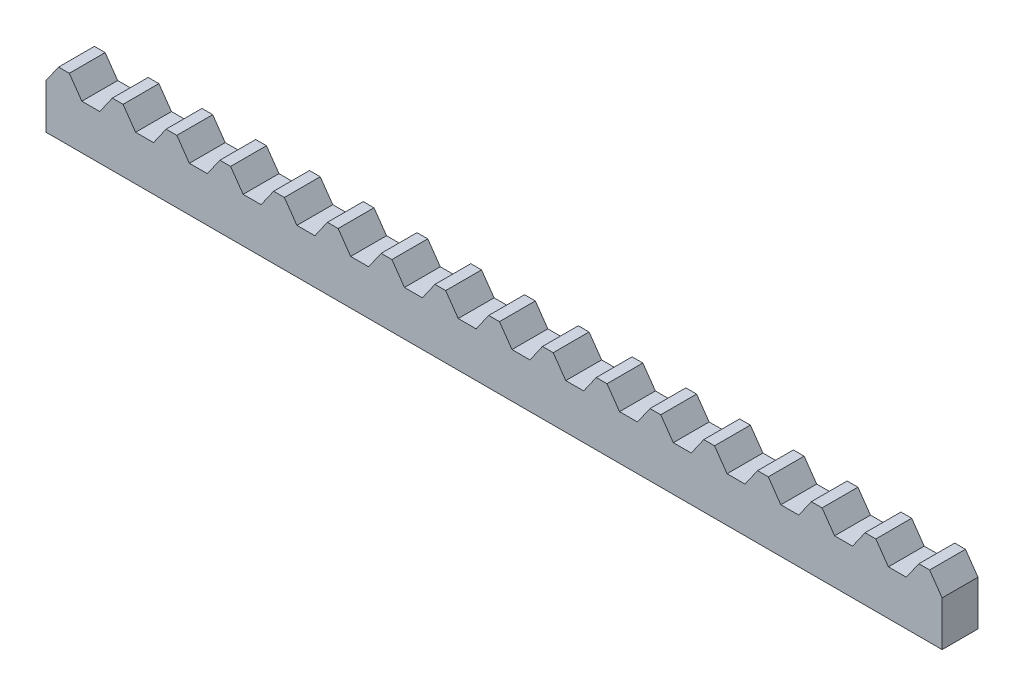
from build123d import *

# Parameters (mm, degrees)
SKETCH2_W           = 100
SKETCH2_H           = 4
BOSS_EXTRUDE1_DEPTH = 5
BOSS_EXTRUDE2_DEPTH = 4


with BuildPart() as part:
    # Sketch2 → Boss-Extrude1 (new body)
    with BuildSketch(Plane(origin=(0, 0, 0), x_dir=(1, 0, 0), z_dir=(0, 1, 0))):
        Rectangle(SKETCH2_W, SKETCH2_H)
    extrude(amount=BOSS_EXTRUDE1_DEPTH)

    # Sketch3 → Boss-Extrude2 (add)
    with BuildSketch(Plane.XY.offset(2)):
        Polygon((-50, 5), (-46, 5), (-47.4, 7), (-48.6, 7), align=None)
        Polygon((-42.6, 7), (-44, 5), (-40, 5), (-41.4, 7), align=None)
        Polygon((-36.6, 7), (-38, 5), (-34, 5), (-35.4, 7), align=None)
        Polygon((-30.6, 7), (-32, 5), (-28, 5), (-29.4, 7), align=None)
        Polygon((-24.6, 7), (-26, 5), (-22, 5), (-23.4, 7), align=None)
        Polygon((-18.6, 7), (-20, 5), (-16, 5), (-17.4, 7), align=None)
        Polygon((-12.6, 7), (-14, 5), (-10, 5), (-11.4, 7), align=None)
        Polygon((-6.6, 7), (-8, 5), (-4, 5), (-5.4, 7), align=None)
        Polygon((-0.6, 7), (-2, 5), (2, 5), (0.6, 7), align=None)
        Polygon((5.4, 7), (4, 5), (8, 5), (6.6, 7), align=None)
        Polygon((11.4, 7), (10, 5), (14, 5), (12.6, 7), align=None)
        Polygon((17.4, 7), (16, 5), (20, 5), (18.6, 7), align=None)
        Polygon((23.4, 7), (22, 5), (26, 5), (24.6, 7), align=None)
        Polygon((29.4, 7), (28, 5), (32, 5), (30.6, 7), align=None)
        Polygon((35.4, 7), (34, 5), (38, 5), (36.6, 7), align=None)
        Polygon((41.4, 7), (40, 5), (44, 5), (42.6, 7), align=None)
        Polygon((47.4, 7), (46, 5), (50, 5), (48.6, 7), align=None)
    extrude(amount=-BOSS_EXTRUDE2_DEPTH)


solid = part.part
